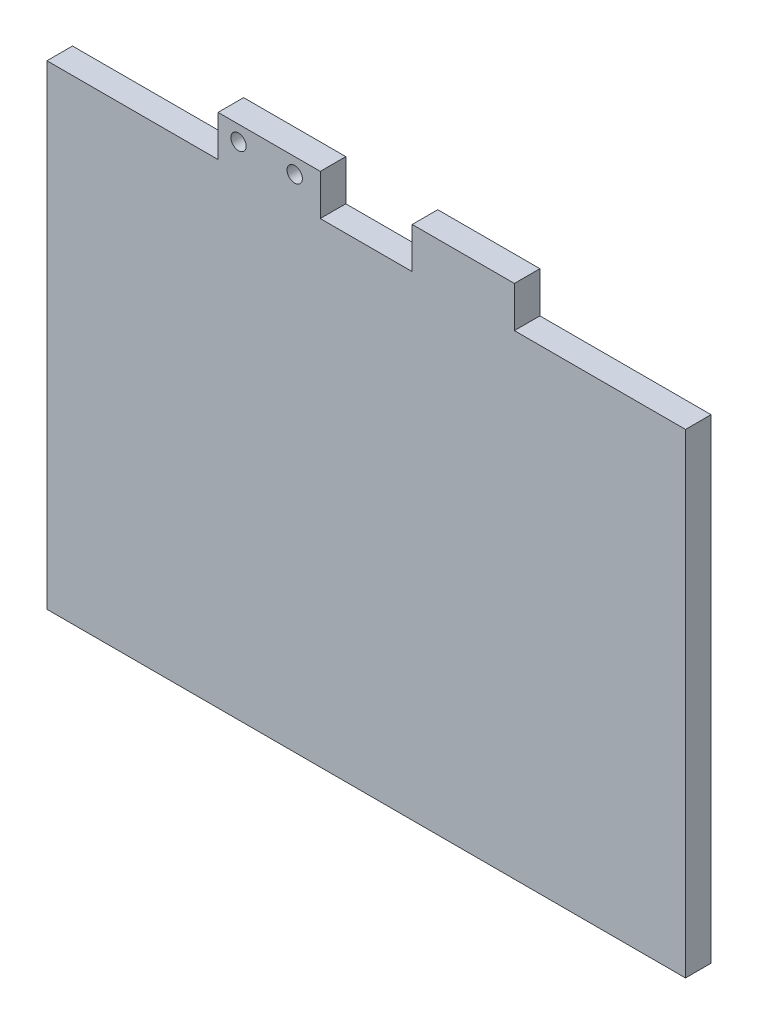
from build123d import *

# Parameters (mm, degrees)
RESSALTO_EXTRUS_O1_DEPTH = 5
ESBO_O2_R                = 1.5
CORTE_EXTRUS_O1_DEPTH    = 10


with BuildPart() as part:
    # Esboço1 → Ressalto-extrusão1 (new body)
    with BuildSketch(Plane.XY):
        Polygon((-1.556986729, 38.142857143), (16.443013271, 38.142857143), (16.443013271, 46.142857143), (36.443013271, 46.142857143), (36.443013271, 38.142857143), (69.943013271, 38.142857143), (69.943013271, -54.857142857), (-55.056986729, -54.857142857), (-55.056986729, 38.142857143), (-21.556986729, 38.142857143), (-21.556986729, 46.142857143), (-1.556986729, 46.142857143), align=None)
    extrude(amount=RESSALTO_EXTRUS_O1_DEPTH)

    # Esboço2 → Corte-extrusão1 (cut)
    with BuildSketch(Plane.XY.offset(5)):
        with Locations((-17.556986729, 43.142857143)):
            Circle(ESBO_O2_R)
        with Locations((-6.556986729, 43.142857143)):
            Circle(ESBO_O2_R)
    extrude(amount=-CORTE_EXTRUS_O1_DEPTH, mode=Mode.SUBTRACT)


solid = part.part
